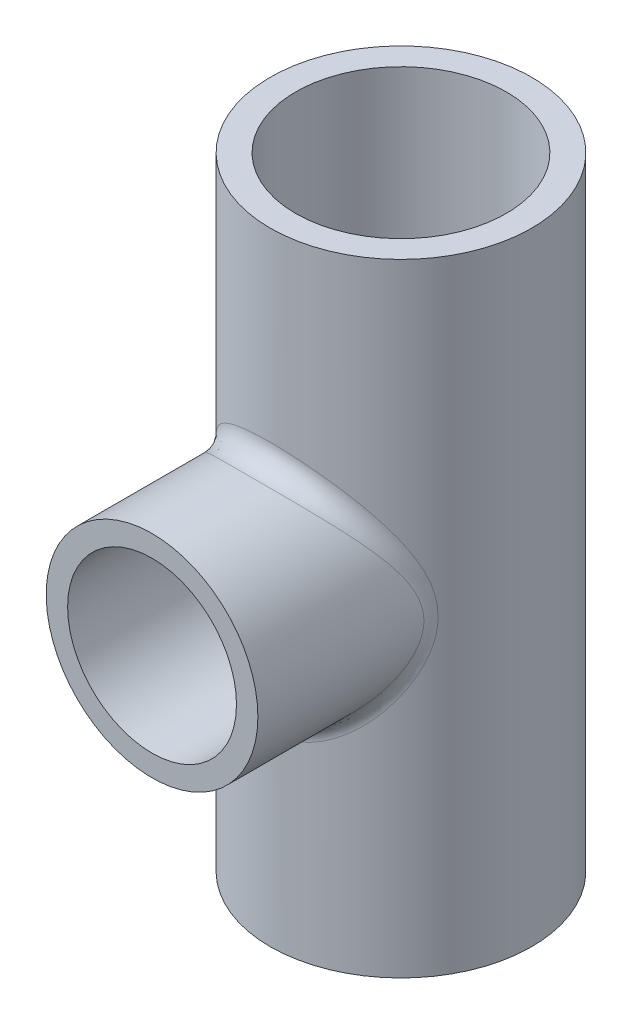
from build123d import *

# Parameters (mm, degrees)
SKETCH2_R           = 0.6565
BOSS_EXTRUDE1_DEPTH = 3.125
SKETCH3_R           = 0.5315
BOSS_EXTRUDE2_DEPTH = 1.25
FILLET1_R           = 0.1
SKETCH4_R           = 0.529
CUT_EXTRUDE1_DEPTH  = 1.25
SKETCH5_R           = 0.529
CUT_EXTRUDE2_DEPTH  = 1.25
SKETCH6_R           = 0.412
CUT_EXTRUDE3_DEPTH  = 2.8750001
SKETCH7_R           = 0.311
CUT_EXTRUDE4_DEPTH  = 1.25
SKETCH8_R           = 0.424
CUT_EXTRUDE5_DEPTH  = 0.69


with BuildPart() as part:
    # Sketch2 → Boss-Extrude1 (new body)
    with BuildSketch(Plane(origin=(0, 0, 0), x_dir=(1, 0, 0), z_dir=(0, 1, 0))):
        Circle(SKETCH2_R)
    extrude(amount=BOSS_EXTRUDE1_DEPTH)

    # Sketch3 → Boss-Extrude2 (add)
    with BuildSketch(Plane.XY):
        with Locations((0, 1.5625)):
            Circle(SKETCH3_R)
    extrude(amount=BOSS_EXTRUDE2_DEPTH)

    # Fillet1
    fillet1_edges = [part.edges().sort_by_distance(p)[0] for p in [
        (-0.5315, 1.5625, 0.385356977),
    ]]
    fillet(fillet1_edges, radius=FILLET1_R)

    # Sketch4 → Cut-Extrude1 (cut)
    with BuildSketch(Plane(origin=(0, 3.125, 0), x_dir=(1, 0, 0), z_dir=(0, 1, 0))):
        Circle(SKETCH4_R)
    extrude(amount=-CUT_EXTRUDE1_DEPTH, mode=Mode.SUBTRACT)

    # Sketch5 → Cut-Extrude2 (cut)
    with BuildSketch(Plane.XZ):
        Circle(SKETCH5_R)
    extrude(amount=-CUT_EXTRUDE2_DEPTH, mode=Mode.SUBTRACT)

    # Sketch6 → Cut-Extrude3 (cut, through all)
    with BuildSketch(Plane(origin=(0, 1.875, 0), x_dir=(1, 0, 0), z_dir=(0, 1, 0))):
        Circle(SKETCH6_R)
    extrude(amount=-CUT_EXTRUDE3_DEPTH, mode=Mode.SUBTRACT)

    # Sketch7 → Cut-Extrude4 (cut)
    with BuildSketch(Plane.XY.offset(1.25)):
        with Locations((0, 1.5625)):
            Circle(SKETCH7_R)
    extrude(amount=-CUT_EXTRUDE4_DEPTH, mode=Mode.SUBTRACT)

    # Sketch8 → Cut-Extrude5 (cut)
    with BuildSketch(Plane.XY.offset(1.25)):
        with Locations((0, 1.5625)):
            Circle(SKETCH8_R)
    extrude(amount=-CUT_EXTRUDE5_DEPTH, mode=Mode.SUBTRACT)


solid = part.part
